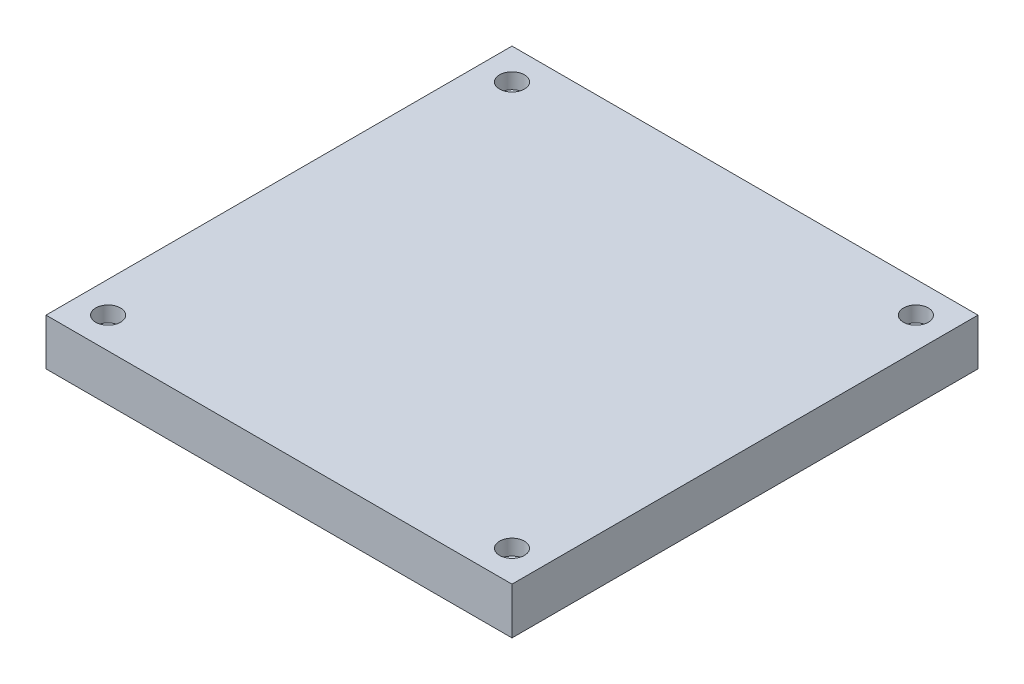
from build123d import *

# Parameters (mm, degrees)
ESBO_O1_W                      = 300
ESBO_O1_H                      = 300
RESSALTO_EXTRUS_O1_DEPTH       = 30
FURO_ROSCADO_DE_M16X2_01_D     = 14
FURO_ROSCADO_DE_M16X2_01_DEPTH = 10
FURO_ROSCADO_DE_M16X2_01_TIP   = 4.206024333
FURO_ROSCADO_DE_M18X2_02_D     = 16
FURO_ROSCADO_DE_M18X2_02_DEPTH = 10
FURO_ROSCADO_DE_M18X2_02_TIP   = 4.806884952


with BuildPart() as part:
    # Esboço1 → Ressalto-extrusão1 (new body)
    with BuildSketch(Plane(origin=(0, 0, 0), x_dir=(1, 0, 0), z_dir=(0, 1, 0))):
        Rectangle(ESBO_O1_W, ESBO_O1_H)
    extrude(amount=RESSALTO_EXTRUS_O1_DEPTH)

    # Furo roscado de M16x2.01
    with Locations(Plane(origin=(0, 0, 0), x_dir=(-1, 0, 0), z_dir=(0, -1, 0))):
        with Locations((55, -71), (-55, -71), (-55, 71), (55, 71)):
            Hole(FURO_ROSCADO_DE_M16X2_01_D / 2, depth=FURO_ROSCADO_DE_M16X2_01_DEPTH)
            with Locations((0, 0, -(FURO_ROSCADO_DE_M16X2_01_DEPTH + FURO_ROSCADO_DE_M16X2_01_TIP / 2))):  # 118° drill point
                Cone(0, FURO_ROSCADO_DE_M16X2_01_D / 2, FURO_ROSCADO_DE_M16X2_01_TIP, mode=Mode.SUBTRACT)

    # Furo roscado de M18x2.02
    with Locations(Plane(origin=(0, 30, 0), x_dir=(1, 0, 0), z_dir=(0, 1, 0))):
        with Locations((-130, 130), (130, 130), (130, -130), (-130, -130)):
            Hole(FURO_ROSCADO_DE_M18X2_02_D / 2, depth=FURO_ROSCADO_DE_M18X2_02_DEPTH)
            with Locations((0, 0, -(FURO_ROSCADO_DE_M18X2_02_DEPTH + FURO_ROSCADO_DE_M18X2_02_TIP / 2))):  # 118° drill point
                Cone(0, FURO_ROSCADO_DE_M18X2_02_D / 2, FURO_ROSCADO_DE_M18X2_02_TIP, mode=Mode.SUBTRACT)


solid = part.part
